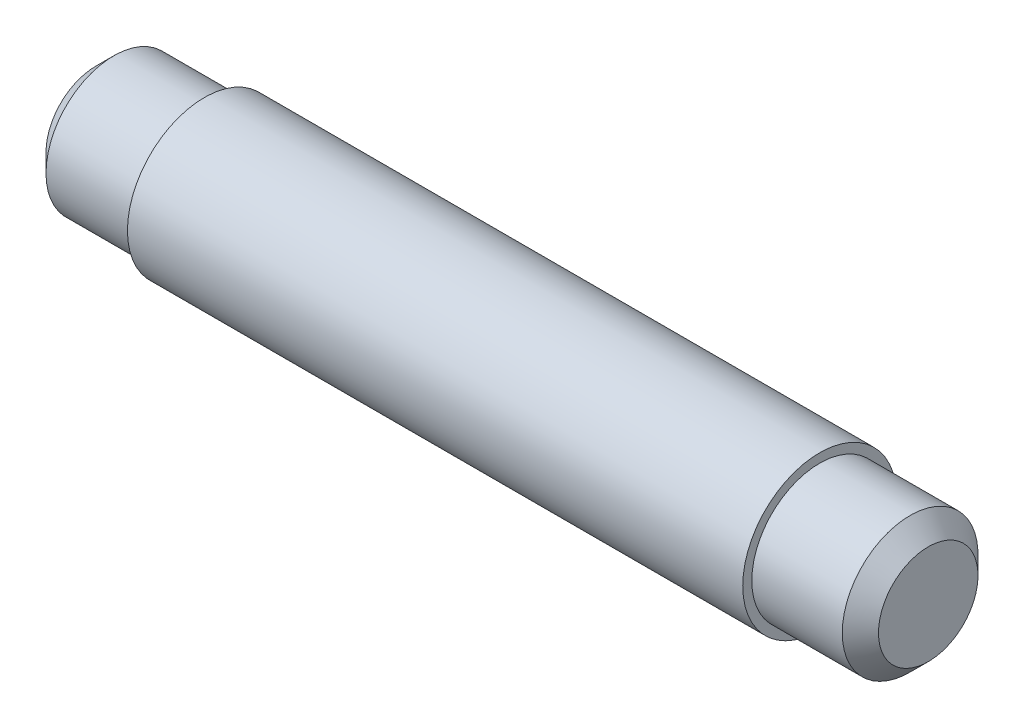
from build123d import *


with BuildPart() as part:
    # Szkic1 → Obrót1 (revolve)
    with BuildSketch(Plane.XY):
        Polygon((0, 0), (46, 0), (46, 2.75), (45, 3.75), (40, 3.75), (40, 4.25), (6, 4.25), (6, 3.75), (1, 3.75), (0, 2.75), align=None)
    revolve(axis=Axis((0, 0, 0), (1, 0, 0)))


solid = part.part
